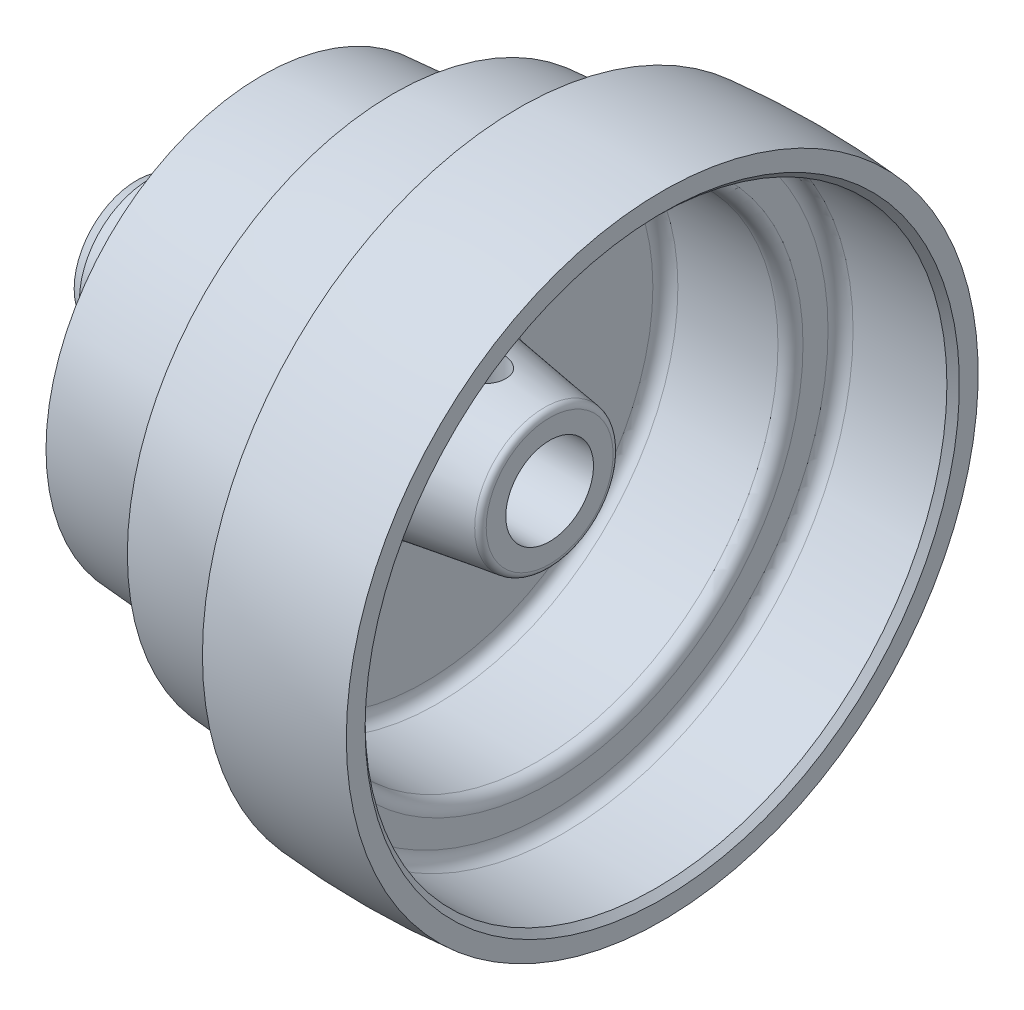
from build123d import *

# Parameters (mm, degrees)
CUT_EXTRUDE1_REACH = 82.963
SKETCH2_R          = 4.7625


with BuildPart() as part:
    # Sketch1 → Revolve1 (revolve)
    with BuildSketch(Plane.XY):
        with BuildLine():
            Line((0, 11.1252), (0, 15.875))
            Line((0, 15.875), (3.160145614, 17.699510921))
            Line((3.160145614, 17.699510921), (60.562458086, 22.004684356))
            ThreePointArc((60.562458086, 22.004684356), (62.652504503, 23.011313573), (63.5, 25.170792165))
            Line((63.5, 25.170792165), (63.5, 46.83125))
            ThreePointArc((63.5, 46.83125), (62.57006403, 49.07631403), (60.325, 50.00625))
            Line((60.325, 50.00625), (33.3375, 50.00625))
            ThreePointArc((33.3375, 50.00625), (32.214967985, 50.471217985), (31.75, 51.59375))
            Line((31.75, 51.59375), (31.75, 54.76875))
            ThreePointArc((31.75, 54.76875), (48.41875, 55.5625), (65.0875, 54.76875))
            Line((65.0875, 54.76875), (65.0875, 67.46875))
            ThreePointArc((65.0875, 67.46875), (80.9625, 68.2625), (96.8375, 67.46875))
            Line((96.8375, 67.46875), (96.8375, 80.16875))
            ThreePointArc((96.8375, 80.16875), (115.09375, 80.9625), (133.35, 80.16875))
            Line((133.35, 80.16875), (133.35, 75.40625))
            Line((133.35, 75.40625), (131.7625, 73.81875))
            Line((131.7625, 73.81875), (107.95, 73.81875))
            ThreePointArc((107.95, 73.81875), (105.70493597, 72.88881403), (104.775, 70.64375))
            Line((104.775, 70.64375), (104.775, 64.29375))
            ThreePointArc((104.775, 64.29375), (103.84506403, 62.04868597), (101.6, 61.11875))
            Line((101.6, 61.11875), (76.2, 61.11875))
            ThreePointArc((76.2, 61.11875), (73.95493597, 60.18881403), (73.025, 57.94375))
            Line((73.025, 57.94375), (73.025, 24.959270061))
            ThreePointArc((73.025, 24.959270061), (73.794174832, 22.88740369), (75.729019062, 21.819397141))
            Line((75.729019062, 21.819397141), (103.422990469, 17.66530143))
            ThreePointArc((103.422990469, 17.66530143), (104.390412584, 17.131298155), (104.775, 16.095364969))
            Line((104.775, 16.095364969), (104.775, 11.1252))
            Line((104.775, 11.1252), (0, 11.1252))
        make_face()
    revolve(axis=Axis((0, 0, 0), (1, 0, 0)))

    # Sketch2 → Cut-Extrude1 (cut, up to next)
    with BuildSketch(Plane(origin=(0, 0, 0), x_dir=(1, 0, 0), z_dir=(0, 1, 0)), mode=Mode.PRIVATE) as cut_extrude1_sk1:
        with Locations((88.9, 0)):
            Circle(SKETCH2_R)
    cut_extrude1_tool1 = extrude(cut_extrude1_sk1.sketch, amount=CUT_EXTRUDE1_REACH, mode=Mode.PRIVATE) & part.part
    add(cut_extrude1_tool1.solids().sort_by_distance((88.9, 0, 0))[0], mode=Mode.SUBTRACT)


solid = part.part
